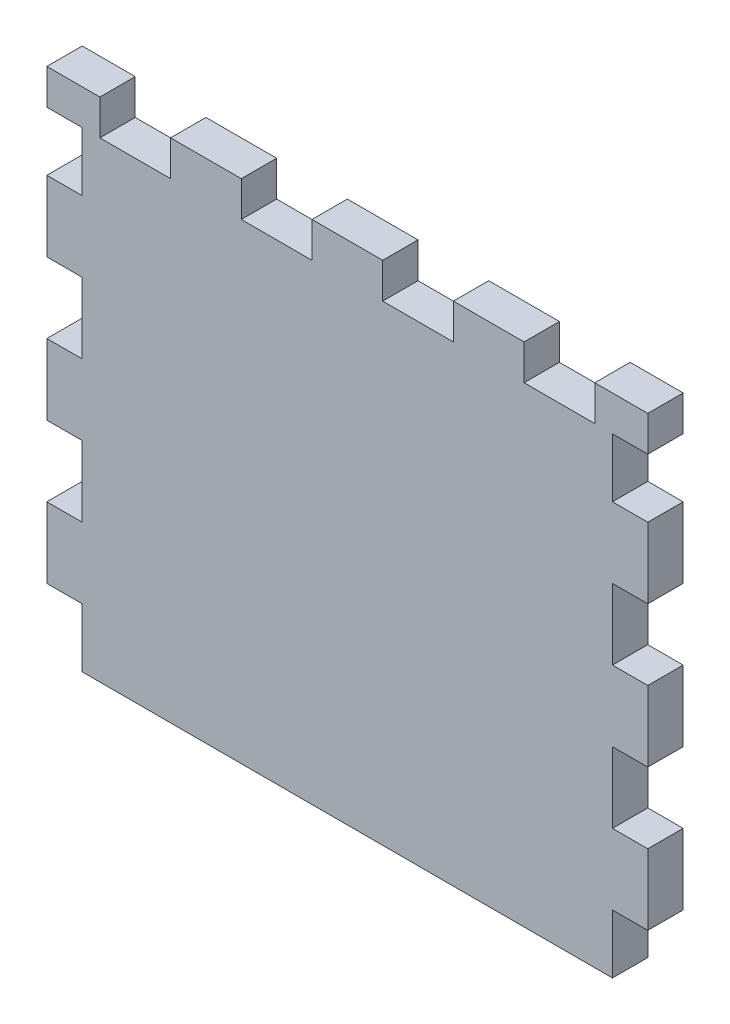
from build123d import *

# Parameters (mm, degrees)
SKETCH1_W               = 45
SKETCH1_H               = 40
BOSS_EXTRUDE1_DEPTH     = 3
SKETCH2_W               = 3
SKETCH2_H               = 6
BOSS_EXTRUDE2_DEPTH     = 3
LPATTERN1_COUNT         = 2
LPATTERN1_PITCH         = 12
LPATTERN1_COL_COUNT     = 2
LPATTERN1_COL_PITCH     = 12
SKETCH3_W               = 6
SKETCH3_H               = 3
BOSS_EXTRUDE3_DEPTH     = 3
LPATTERN2_COUNT         = 3
LPATTERN2_PITCH         = 12
LPATTERN2_COL_COUNT     = 3
LPATTERN2_COL_PITCH     = 12
SKETCH6_W               = 1.5
SKETCH6_H               = 3
CUT_EXTRUDE2_DEPTH      = 3
MIRROR1_COPY_1_SKETCH_W = 3
MIRROR1_COPY_1_SKETCH_H = 6
MIRROR1_COPY_1_DEPTH    = 3
MIRROR1_COPY_2_SKETCH_W = 3
MIRROR1_COPY_2_SKETCH_H = 6
MIRROR1_COPY_2_DEPTH    = 3


with BuildPart() as part:
    # Sketch1 → Boss-Extrude1 (new body)
    with BuildSketch(Plane.XY):
        Rectangle(SKETCH1_W, SKETCH1_H)
    extrude(amount=BOSS_EXTRUDE1_DEPTH)

    # Sketch2 → Boss-Extrude2 (add)
    with BuildSketch(Plane.ZY.offset(22.5)):
        with Locations((1.5, 0)):
            Rectangle(SKETCH2_W, SKETCH2_H)
    boss_extrude2 = extrude(amount=BOSS_EXTRUDE2_DEPTH)

    # LPattern1: Boss-Extrude2 ×2
    with Locations(*[(0, -i * LPATTERN1_PITCH, 0) for i in range(1, LPATTERN1_COUNT)]):
        add(boss_extrude2)

    # LPattern1 col: Boss-Extrude2 ×2
    with Locations(*[(0, i * LPATTERN1_COL_PITCH, 0) for i in range(1, LPATTERN1_COL_COUNT)]):
        add(boss_extrude2)

    # Sketch3 → Boss-Extrude3 (add)
    with BuildSketch(Plane(origin=(0, 20, 0), x_dir=(1, 0, 0), z_dir=(0, 1, 0))):
        with Locations((0, -1.5)):
            Rectangle(SKETCH3_W, SKETCH3_H)
    boss_extrude3 = extrude(amount=BOSS_EXTRUDE3_DEPTH)

    # LPattern2: Boss-Extrude3 ×3
    with Locations(*[(-i * LPATTERN2_PITCH, 0, 0) for i in range(1, LPATTERN2_COUNT)]):
        add(boss_extrude3)

    # LPattern2 col: Boss-Extrude3 ×3
    with Locations(*[(i * LPATTERN2_COL_PITCH, 0, 0) for i in range(1, LPATTERN2_COL_COUNT)]):
        add(boss_extrude3)

    # Sketch6 → Cut-Extrude2 (cut)
    with BuildSketch(Plane(origin=(0, 23, 0), x_dir=(1, 0, 0), z_dir=(0, 1, 0))):
        with Locations((26.25, -1.5)):
            Rectangle(SKETCH6_W, SKETCH6_H)
    cut_extrude2 = extrude(amount=-CUT_EXTRUDE2_DEPTH, mode=Mode.SUBTRACT)

    # Mirror1: Boss-Extrude2 across plane
    add(boss_extrude2.mirror(Plane(origin=(0, 0, 0), x_dir=(0, 0, 1), z_dir=(1, 0, 0))))

    # Mirror1 copy 1 sketch → Mirror1 copy 1 (add)
    with BuildSketch(Plane(origin=(22.5, -12, 0), x_dir=(0, 0, 1), z_dir=(1, 0, 0))):
        with Locations((1.5, 0)):
            Rectangle(MIRROR1_COPY_1_SKETCH_W, MIRROR1_COPY_1_SKETCH_H)
    extrude(amount=MIRROR1_COPY_1_DEPTH)

    # Mirror1 copy 2 sketch → Mirror1 copy 2 (add)
    with BuildSketch(Plane(origin=(22.5, 12, 0), x_dir=(0, 0, 1), z_dir=(1, 0, 0))):
        with Locations((1.5, 0)):
            Rectangle(MIRROR1_COPY_2_SKETCH_W, MIRROR1_COPY_2_SKETCH_H)
    extrude(amount=MIRROR1_COPY_2_DEPTH)

    # Mirror2: Cut-Extrude2 across plane
    add(cut_extrude2.mirror(Plane(origin=(0, 0, 0), x_dir=(0, 0, 1), z_dir=(1, 0, 0))), mode=Mode.SUBTRACT)


solid = part.part
